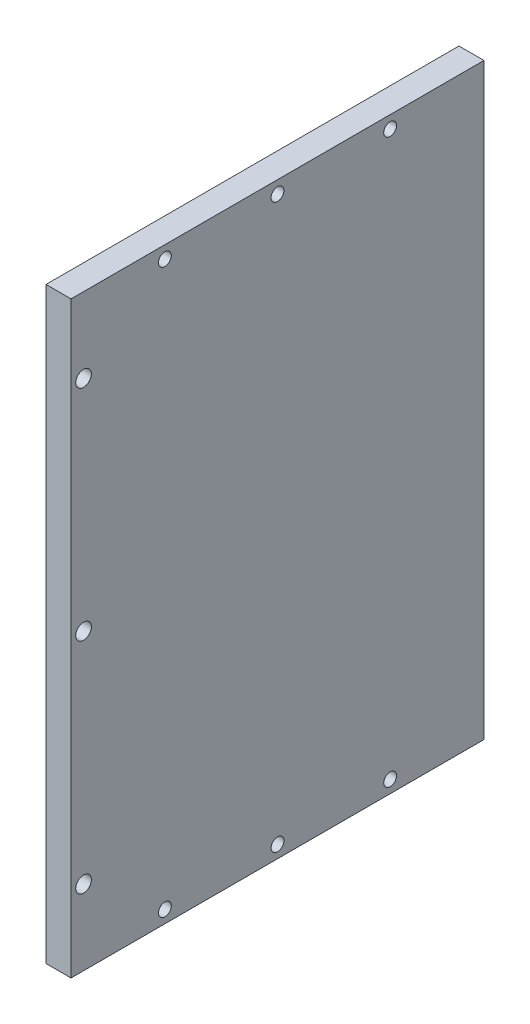
from build123d import *

# Parameters (mm, degrees)
SKETCH_1_R               = 1.25
EXTRUDE_1_DEPTH          = 4
HOLE_WIZARD_M2_5_1_D     = 2.05
HOLE_WIZARD_M2_5_2_D     = 2.05
HOLE_WIZARD_M2_5_2_DEPTH = 7.25
HOLE_WIZARD_M2_5_2_TIP   = 0.615882135


with BuildPart() as part:
    # 草图1 → 凸台-拉伸1 (new body)
    with BuildSketch(Plane(origin=(0, 0, 0), x_dir=(0, 0, -1), z_dir=(1, 0, 0))):
        Polygon((0, 0), (0, 47), (66, 47), (66, -47), (0, -47), align=None)
        with Locations((2, 0)):
            Circle(SKETCH_1_R, mode=Mode.SUBTRACT)
        with Locations((2, 35)):
            Circle(SKETCH_1_R, mode=Mode.SUBTRACT)
        with Locations((2, -35)):
            Circle(SKETCH_1_R, mode=Mode.SUBTRACT)
    extrude(amount=EXTRUDE_1_DEPTH)

    # M2.5 螺纹孔1 (through all)
    with Locations(Plane(origin=(4, 0, 0), x_dir=(0, 0, -1), z_dir=(1, 0, 0))):
        with Locations((15, 45), (51, 45), (15, -45), (51, -45), (33, -45), (33, 45)):
            Hole(HOLE_WIZARD_M2_5_1_D / 2)

    # M2.5 螺纹孔2
    with Locations(Plane(origin=(0, 0, -66), x_dir=(-1, 0, 0), z_dir=(0, 0, -1))):
        with Locations((-2, 35), (-2, 0), (-2, -35)):
            Hole(HOLE_WIZARD_M2_5_2_D / 2, depth=HOLE_WIZARD_M2_5_2_DEPTH)
            with Locations((0, 0, -(HOLE_WIZARD_M2_5_2_DEPTH + HOLE_WIZARD_M2_5_2_TIP / 2))):  # 118° drill point
                Cone(0, HOLE_WIZARD_M2_5_2_D / 2, HOLE_WIZARD_M2_5_2_TIP, mode=Mode.SUBTRACT)


solid = part.part
